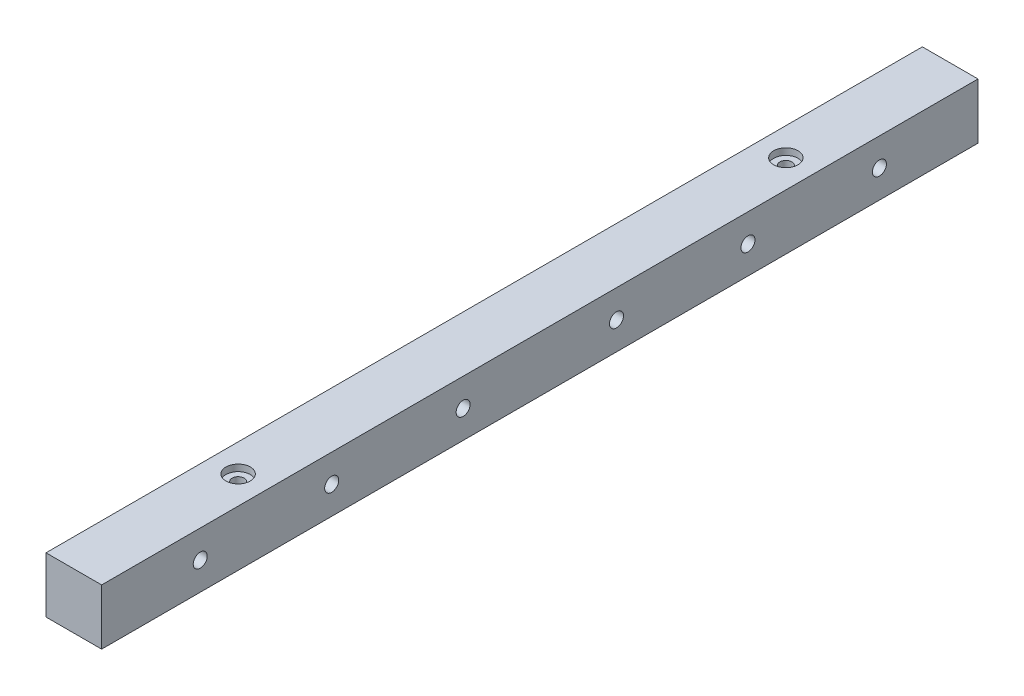
from build123d import *

# Parameters (mm, degrees)
BOSS_EXTRUDE1_DEPTH      = 200
BOSS_EXTRUDE1_DEPTH_BACK = 200
SKETCH1_W                = 25.4
SKETCH1_H                = 25.4
SKETCH5_R                = 3.2
CUT_EXTRUDE1_DEPTH       = 203.006064265
SKETCH6_R                = 4
CUT_EXTRUDE2_DEPTH       = 3


with BuildPart() as part:
    # Sketch1 → Boss-Extrude1 (new, two sides: drawn at the far end of the back side and taken through both)
    with BuildSketch(Plane.XY.offset(-BOSS_EXTRUDE1_DEPTH_BACK)):
        Rectangle(SKETCH1_W, SKETCH1_H)
    extrude(amount=BOSS_EXTRUDE1_DEPTH + BOSS_EXTRUDE1_DEPTH_BACK)

    # Sketch4 → Cut-Revolve1 (revolve, cut)
    with BuildSketch(Plane(origin=(0, 0, 0), x_dir=(0, 0, -1), z_dir=(1, 0, 0))):
        Polygon((-125, -12.7), (-131, -12.7), (-131, 2.3), (-127.75, 4.176388375), (-127.75, 9.7), (-130.55625, 9.7), (-130.55625, 12.7), (-125, 12.7), align=None)
    cut_revolve1 = revolve(axis=Axis((0, 23.510725719, 125), (0, -1, 0)), mode=Mode.SUBTRACT)

    # Mirror1: Cut-Revolve1 across plane
    add(cut_revolve1.mirror(Plane.XY), mode=Mode.SUBTRACT)

    # Sketch5 → Cut-Extrude1 (cut, through all)
    with BuildSketch(Plane(origin=(12.7, 0, 0), x_dir=(0, 0, -1), z_dir=(1, 0, 0))):
        with Locations((-155, 0)):
            Circle(SKETCH5_R)
        with Locations((-95, 0)):
            Circle(SKETCH5_R)
        with Locations((-35, 0)):
            Circle(SKETCH5_R)
        with Locations((35, 0)):
            Circle(SKETCH5_R)
        with Locations((95, 0)):
            Circle(SKETCH5_R)
        with Locations((155, 0)):
            Circle(SKETCH5_R)
    extrude(amount=-CUT_EXTRUDE1_DEPTH, mode=Mode.SUBTRACT)

    # Sketch6 → Cut-Extrude2 (cut)
    with BuildSketch(Plane.ZY.offset(12.7)):
        with Locations((-155, 0)):
            Circle(SKETCH6_R)
        with Locations((-95, 0)):
            Circle(SKETCH6_R)
        with Locations((-35, 0)):
            Circle(SKETCH6_R)
        with Locations((35, 0)):
            Circle(SKETCH6_R)
        with Locations((95, 0)):
            Circle(SKETCH6_R)
        with Locations((155, 0)):
            Circle(SKETCH6_R)
    extrude(amount=-CUT_EXTRUDE2_DEPTH, mode=Mode.SUBTRACT)


solid = part.part
